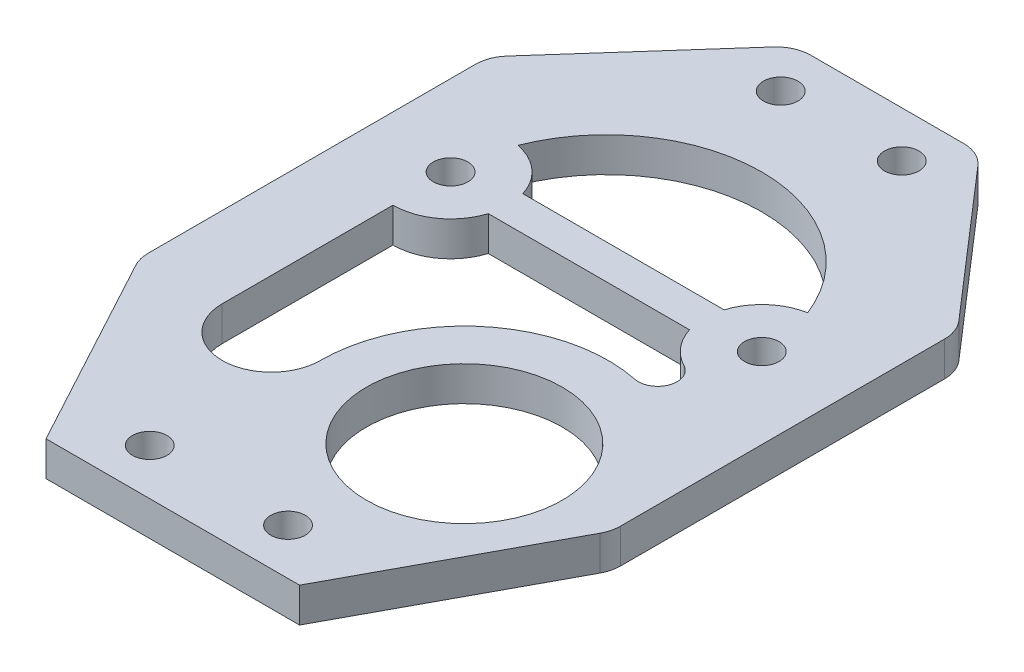
from build123d import *

# Parameters (mm, degrees)
SKETCH1_R           = 8.5
SKETCH1_R_2         = 1.5
BOSS_EXTRUDE1_DEPTH = 3
FILLET1_R           = 3


with BuildPart() as part:
    # Sketch1 → Boss-Extrude1 (new body)
    with BuildSketch(Plane(origin=(0, 0, 0), x_dir=(1, 0, 0), z_dir=(0, 1, 0))):
        Polygon((-11, 0), (11, 0), (20.489621783, 17.605313925), (20.489621783, 47.605313925), (8, 62), (-8, 62), (-20.509243816, 47.910305032), (-20.509243816, 17.610706132), align=None)
        with Locations((7.519679741, 17.780252273)):
            Circle(SKETCH1_R, mode=Mode.SUBTRACT)
        with Locations((6, 4)):
            Circle(SKETCH1_R_2, mode=Mode.SUBTRACT)
        with Locations((-6, 4)):
            Circle(SKETCH1_R_2, mode=Mode.SUBTRACT)
        with Locations((-5.25, 57.999859765)):
            Circle(SKETCH1_R_2, mode=Mode.SUBTRACT)
        with Locations((5.25, 57.999859765)):
            Circle(SKETCH1_R_2, mode=Mode.SUBTRACT)
        with Locations((-13.5, 37.605313925)):
            Circle(SKETCH1_R_2, mode=Mode.SUBTRACT)
        with Locations((13.5, 37.605313925)):
            Circle(SKETCH1_R_2, mode=Mode.SUBTRACT)
        with BuildLine():
            Line((-8.730303993, 39.105313925), (8.730303993, 39.105313925))
            ThreePointArc((8.730303993, 39.105313925), (10.179901517, 41.34388933), (12.574074074, 42.518832133))
            ThreePointArc((12.574074074, 42.518832133), (0, 51.105313925), (-12.574074074, 42.518832133))
            ThreePointArc((-12.574074074, 42.518832133), (-10.179901517, 41.34388933), (-8.730303993, 39.105313925))
        make_face(mode=Mode.SUBTRACT)
        with BuildLine():
            Line((-8.730303993, 36.105313925), (8.730303993, 36.105313925))
            ThreePointArc((8.730303993, 36.105313925), (9.667400631, 34.394210987), (11.187975781, 33.171969363))
            ThreePointArc((11.187975781, 33.171969363), (11.998189223, 31.105465162), (10.062695821, 30.018841621))
            ThreePointArc((10.062695821, 30.018841621), (-0.366780245, 27.478383479), (-4.980318958, 17.785955551))
            ThreePointArc((-4.980318958, 17.785955551), (-9.241131059, 13.528058523), (-13.5, 17.787899155))
            Line((-13.5, 17.787899155), (-13.5, 32.605313925))
            ThreePointArc((-13.5, 32.605313925), (-10.541960108, 33.574185051), (-8.730303993, 36.105313925))
        make_face(mode=Mode.SUBTRACT)
    extrude(amount=BOSS_EXTRUDE1_DEPTH)

    # Fillet1
    fillet1_edges = [part.edges().sort_by_distance(p)[0] for p in [
        (-20.509243816, 1.5, -17.610706132),
        (-20.509243816, 1.5, -47.910305032),
        (-8, 1.5, -62),
        (8, 1.5, -62),
        (20.489621783, 1.5, -47.605313925),
        (20.489621783, 1.5, -17.605313925),
    ]]
    fillet(fillet1_edges, radius=FILLET1_R)


solid = part.part
